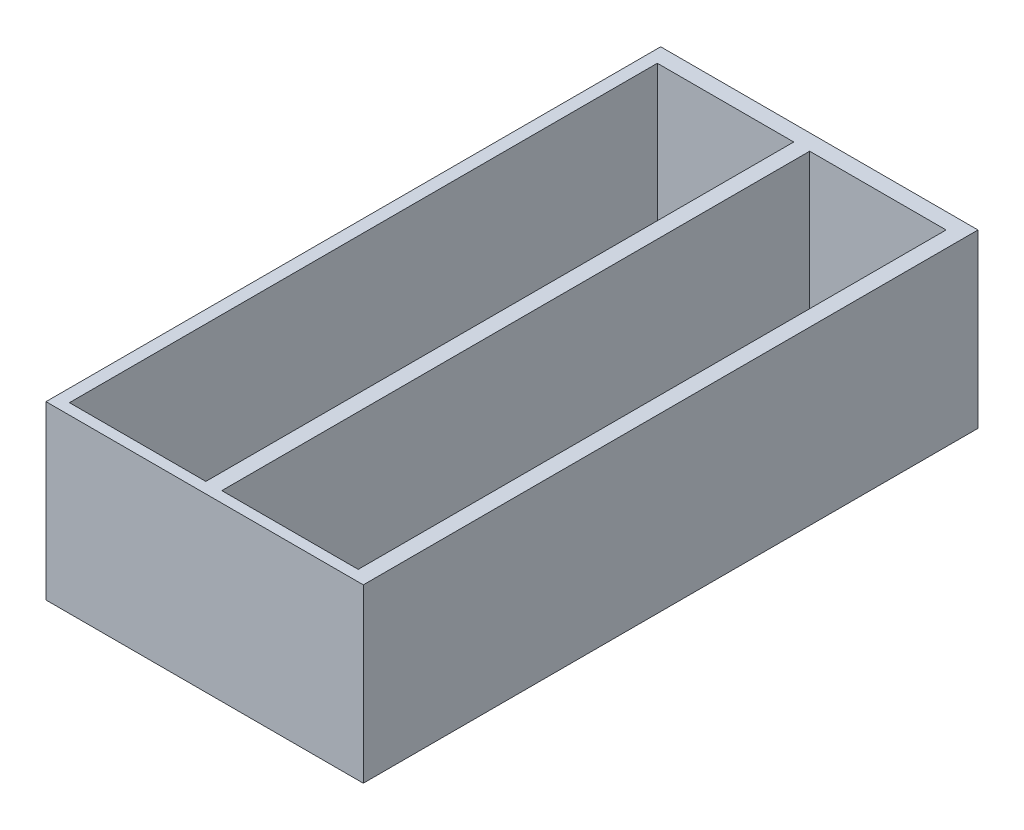
from build123d import *

# Parameters (mm, degrees)
SKETCH1_W           = 39.78
SKETCH1_H           = 77.06
BOSS_EXTRUDE1_DEPTH = 21.54
SKETCH2_W           = 17.1
SKETCH2_H           = 73.7
CUT_EXTRUDE1_DEPTH  = 19.54


with BuildPart() as part:
    # Sketch1 → Boss-Extrude1 (new body)
    with BuildSketch(Plane(origin=(0, 0, 0), x_dir=(1, 0, 0), z_dir=(0, 1, 0))):
        with Locations((-7.381730769, 20.146634615)):
            Rectangle(SKETCH1_W, SKETCH1_H)
    extrude(amount=BOSS_EXTRUDE1_DEPTH)

    # Sketch2 → Cut-Extrude1 (cut)
    with BuildSketch(Plane(origin=(0, 21.54, 0), x_dir=(1, 0, 0), z_dir=(0, 1, 0))):
        with Locations((1.958269231, 19.826634615)):
            Rectangle(SKETCH2_W, SKETCH2_H)
        with Locations((-17.141730769, 19.826634615)):
            Rectangle(SKETCH2_W, SKETCH2_H)
    extrude(amount=-CUT_EXTRUDE1_DEPTH, mode=Mode.SUBTRACT)


solid = part.part
